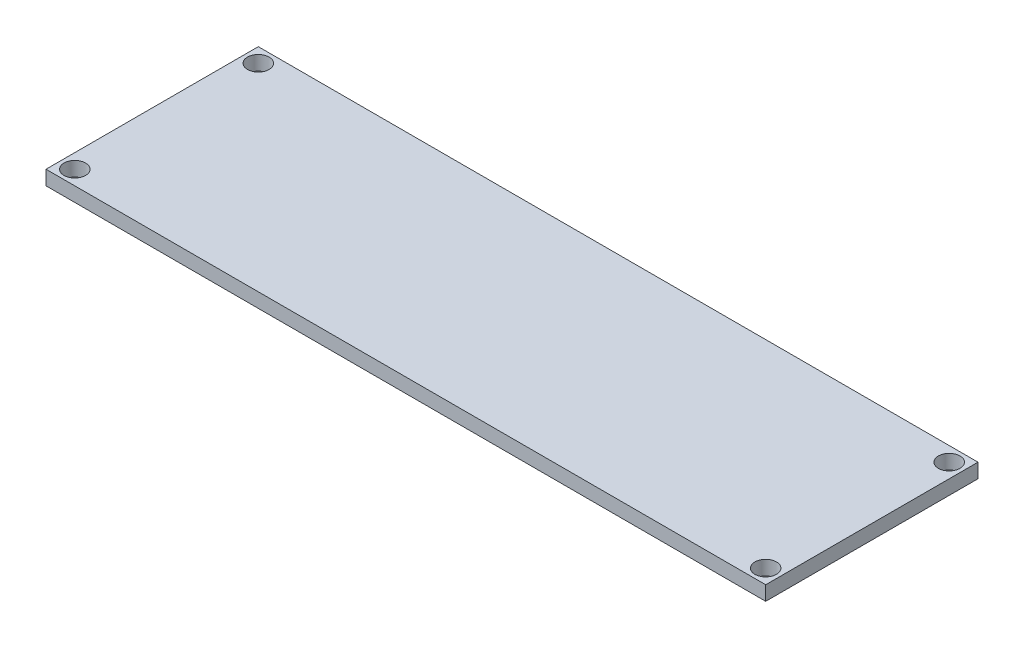
from build123d import *

# Parameters (mm, degrees)
SKETCH1_W           = 100
SKETCH1_H           = 29.5
BOSS_EXTRUDE1_DEPTH = 2
SKETCH2_R           = 1.5
CUT_EXTRUDE1_DEPTH  = 2


with BuildPart() as part:
    # Sketch1 → Boss-Extrude1 (new body)
    with BuildSketch(Plane(origin=(0, 0, 0), x_dir=(1, 0, 0), z_dir=(0, 1, 0))):
        with Locations((9.973320872, 2.269230769)):
            Rectangle(SKETCH1_W, SKETCH1_H)
    extrude(amount=BOSS_EXTRUDE1_DEPTH)

    # Sketch2 → Cut-Extrude1 (cut)
    with BuildSketch(Plane(origin=(0, 2, 0), x_dir=(1, 0, 0), z_dir=(0, 1, 0))):
        with Locations(Location((57.973320872, -10.480769231, 0), (0, 0, 270))):  # turned: the seam where the file's is
            Circle(SKETCH2_R)
        with Locations(Location((-38.026679128, -10.480769231, 0), (0, 0, 270))):  # turned: the seam where the file's is
            Circle(SKETCH2_R)
        with Locations(Location((-38.026679128, 15.019230769, 0), (0, 0, 270))):  # turned: the seam where the file's is
            Circle(SKETCH2_R)
        with Locations(Location((57.973320872, 15.019230769, 0), (0, 0, 270))):  # turned: the seam where the file's is
            Circle(SKETCH2_R)
    extrude(amount=-CUT_EXTRUDE1_DEPTH, mode=Mode.SUBTRACT)


solid = part.part
